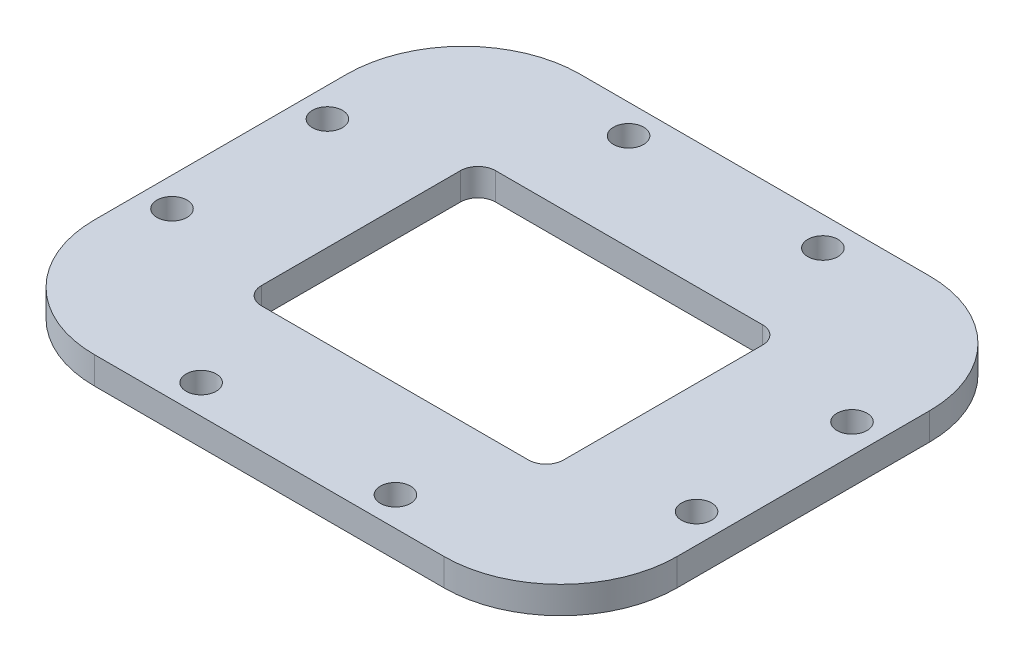
from build123d import *

# Parameters (mm, degrees)
SKETCH_1_W          = 60
SKETCH_1_H          = 50
SKETCH_1_W_2        = 29.5
SKETCH_1_H_2        = 22.5
EXTRUDE_1_DEPTH     = 2.8
SKETCH_8_R          = 1.55
CUT_EXTRUDE_2_DEPTH = 10
FILLET_1_R          = 1
FILLET_2_R          = 12
CUT_EXTRUDE_3_DEPTH = 10


with BuildPart() as part:
    # 草图1 → 凸台-拉伸1 (new body)
    with BuildSketch(Plane(origin=(0, 0, 0), x_dir=(1, 0, 0), z_dir=(0, 1, 0))):
        Rectangle(SKETCH_1_W, SKETCH_1_H)
        Rectangle(SKETCH_1_W_2, SKETCH_1_H_2, mode=Mode.SUBTRACT)
    extrude(amount=EXTRUDE_1_DEPTH)

    # 草图8 → 切除-拉伸2 (cut)
    with BuildSketch(Plane.XZ):
        with Locations((27, 8)):
            Circle(SKETCH_8_R)
        with Locations((10, 22)):
            Circle(SKETCH_8_R)
        with Locations((-10, 22)):
            Circle(SKETCH_8_R)
        with Locations((-27, 8)):
            Circle(SKETCH_8_R)
        with Locations((-27, -8)):
            Circle(SKETCH_8_R)
        with Locations((-10, -22)):
            Circle(SKETCH_8_R)
        with Locations((10, -22)):
            Circle(SKETCH_8_R)
        with Locations((27, -8)):
            Circle(SKETCH_8_R)
    extrude(amount=-CUT_EXTRUDE_2_DEPTH, mode=Mode.SUBTRACT)

    # 圆角1
    fillet_1_edges = [part.edges().sort_by_distance(p)[0] for p in [
        (14.75, 1.4, 11.25),
        (14.75, 1.4, -11.25),
        (-14.75, 1.4, -11.25),
        (-14.75, 1.4, 11.25),
    ]]
    fillet(fillet_1_edges, radius=FILLET_1_R)

    # 圆角2
    fillet_2_edges = [part.edges().sort_by_distance(p)[0] for p in [
        (30, 1.4, 25),
        (-30, 1.4, 25),
        (-30, 1.4, -25),
        (30, 1.4, -25),
    ]]
    fillet(fillet_2_edges, radius=FILLET_2_R)

    # 草图9 → 切除-拉伸3 (cut)
    with BuildSketch(Plane.XZ):
        with BuildLine():
            Line((-13.75, 12.05), (13.75, 12.05))
            ThreePointArc((13.75, 12.05), (15.022792206, 11.522792206), (15.55, 10.25))
            Line((15.55, 10.25), (15.55, -10.25))
            ThreePointArc((15.55, -10.25), (15.022792206, -11.522792206), (13.75, -12.05))
            Line((13.75, -12.05), (-13.75, -12.05))
            ThreePointArc((-13.75, -12.05), (-15.022792206, -11.522792206), (-15.55, -10.25))
            Line((-15.55, -10.25), (-15.55, 10.25))
            ThreePointArc((-15.55, 10.25), (-15.022792206, 11.522792206), (-13.75, 12.05))
        make_face()
    extrude(amount=-CUT_EXTRUDE_3_DEPTH, mode=Mode.SUBTRACT)


solid = part.part
